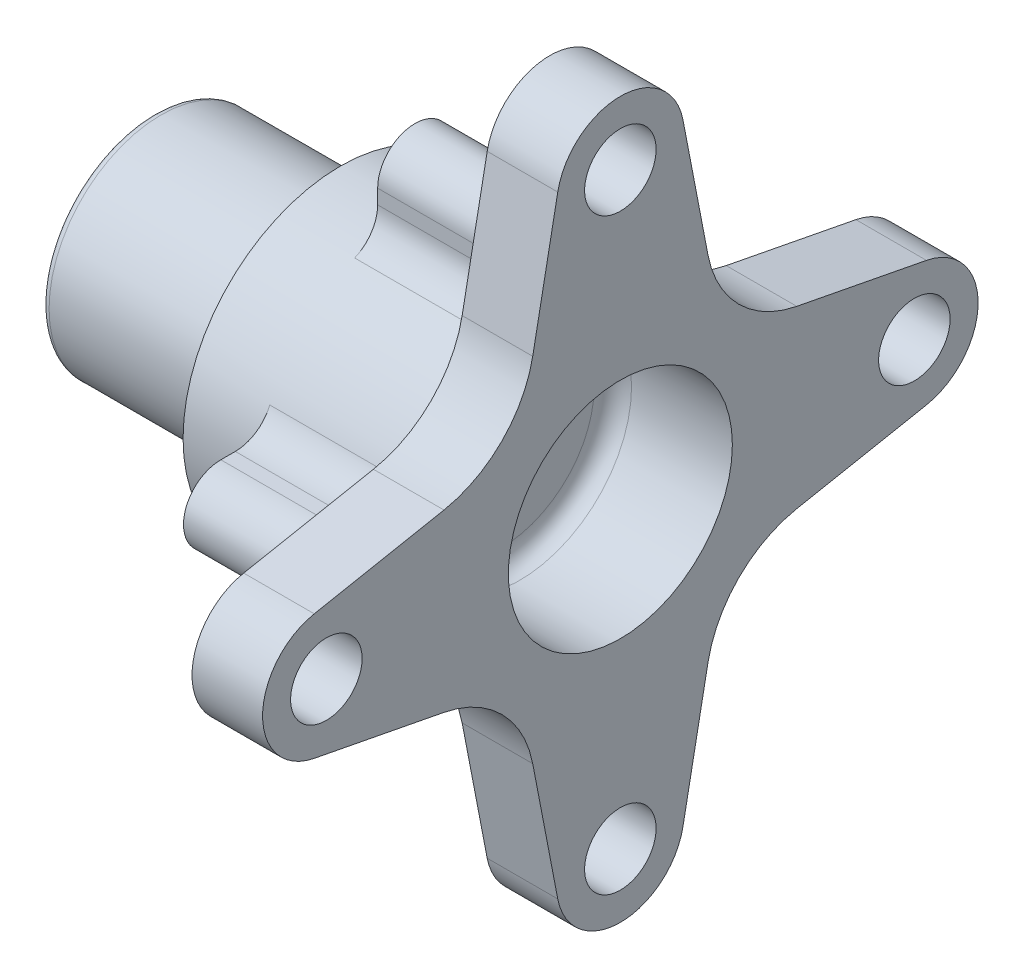
from build123d import *

# Parameters (mm, degrees)
SKETCH2_R                       = 61.1125
SKETCH2_R_2                     = 6.07949
CUT_EXTRUDE1_DEPTH              = 12
F_3_16_0_1875_DOWEL_HOLE1_D     = 4.7625
F_3_16_0_1875_DOWEL_HOLE1_DEPTH = 12.7
F_3_16_0_1875_DOWEL_HOLE1_TIP   = 1.430799
CUT_EXTRUDE3_DEPTH              = 22.925
SKETCH6_R                       = 19.05
CUT_EXTRUDE4_DEPTH              = 20.32
FILLET8_R                       = 6.35
FILLET7_R                       = 1.27
FILLET9_R                       = 3.175
F_1_4_20_TAPPED_HOLE1_D         = 5.1054
F_1_4_20_TAPPED_HOLE1_DEPTH     = 16.51
F_1_4_20_TAPPED_HOLE1_TIP       = 1.533817


with BuildPart() as part:
    # Sketch1 → Revolve1 (revolve)
    with BuildSketch(Plane.XY):
        Polygon((479.941353, 251.46), (511.691353, 251.46), (511.691353, 259.155045), (524.391353, 259.155045), (524.391353, 271.78), (547.316353, 271.78), (547.316353, 293.5225), (559.316353, 293.5225), (559.316353, 238.76), (479.941353, 238.76), align=None)
    revolve(axis=Axis((439.541353, 232.41, 0), (1, 0, 0)))

    # Sketch2 → Cut-Extrude1 (cut)
    with BuildSketch(Plane(origin=(559.316353, 0, 0), x_dir=(0, 0, -1), z_dir=(1, 0, 0))):
        with Locations((0, 232.41)):
            Circle(SKETCH2_R)
        with BuildLine():
            ThreePointArc((-10.645415, 284.46521), (0, 293.25199), (10.645415, 284.46521))
            Line((10.645415, 284.46521), (14.903909, 262.407394))
            ThreePointArc((14.903909, 262.407394), (20.138131, 252.548131), (29.997394, 247.313909))
            Line((29.997394, 247.313909), (52.05521, 243.055415))
            ThreePointArc((52.05521, 243.055415), (58.361558, 239.311673), (60.84199, 232.41))
            ThreePointArc((60.84199, 232.41), (58.361558, 225.508327), (52.05521, 221.764585))
            Line((52.05521, 221.764585), (29.997394, 217.506091))
            ThreePointArc((29.997394, 217.506091), (20.138131, 212.271869), (14.903909, 202.412606))
            Line((14.903909, 202.412606), (10.645415, 180.35479))
            ThreePointArc((10.645415, 180.35479), (0, 171.56801), (-10.645415, 180.35479))
            Line((-10.645415, 180.35479), (-14.903909, 202.412606))
            ThreePointArc((-14.903909, 202.412606), (-14.993612, 202.849678), (-15.093527, 203.284529))
            ThreePointArc((-15.093527, 203.284529), (-19.618803, 211.731698), (-27.684188, 216.906866))
            ThreePointArc((-27.684188, 216.906866), (-28.831386, 217.242784), (-29.997394, 217.506091))
            Line((-29.997394, 217.506091), (-52.05521, 221.764585))
            ThreePointArc((-52.05521, 221.764585), (-60.84199, 232.41), (-52.05521, 243.055415))
            Line((-52.05521, 243.055415), (-29.997394, 247.313909))
            ThreePointArc((-29.997394, 247.313909), (-20.138131, 252.548131), (-14.903909, 262.407394))
            Line((-14.903909, 262.407394), (-10.645415, 284.46521))
        make_face(mode=Mode.SUBTRACT)
        with Locations((-50, 232.41)):
            Circle(SKETCH2_R_2)
        with Locations((0, 182.41)):
            Circle(SKETCH2_R_2)
        with Locations((50, 232.41)):
            Circle(SKETCH2_R_2)
        with Locations((0, 282.41)):
            Circle(SKETCH2_R_2)
    extrude(amount=-CUT_EXTRUDE1_DEPTH, mode=Mode.SUBTRACT)

    # 3/16 (0.1875) Dowel Hole1
    with Locations(Plane(origin=(479.941353, 238.76, -10.998523), x_dir=(0, 0, -1), z_dir=(-1, 0, 0))):
        with Locations((0, 0), (-10.998523, -6.35), (-21.997045, 0), (-21.997045, 12.7), (-10.998523, 19.05), (0, 12.7)):
            Hole(F_3_16_0_1875_DOWEL_HOLE1_D / 2, depth=F_3_16_0_1875_DOWEL_HOLE1_DEPTH)
            with Locations((0, 0, -(F_3_16_0_1875_DOWEL_HOLE1_DEPTH + F_3_16_0_1875_DOWEL_HOLE1_TIP / 2))):  # 118° drill point
                Cone(0, F_3_16_0_1875_DOWEL_HOLE1_D / 2, F_3_16_0_1875_DOWEL_HOLE1_TIP, mode=Mode.SUBTRACT)

    # Sketch5 → Cut-Extrude3 (cut)
    with BuildSketch(Plane.ZY.offset(-524.391353)):
        with BuildLine():
            ThreePointArc((-33.02, 226.06), (-37.510128, 227.919872), (-39.37, 232.41))
            ThreePointArc((-39.37, 232.41), (-27.838794, 204.571206), (0, 193.04))
            ThreePointArc((0, 193.04), (-4.490128, 194.899872), (-6.35, 199.39))
            Line((-6.35, 199.39), (-6.35, 206.42972))
            ThreePointArc((-6.35, 206.42972), (-18.911603, 213.498397), (-25.98028, 226.06))
            Line((-25.98028, 226.06), (-33.02, 226.06))
        make_face()
        with BuildLine():
            Line((-6.35, 258.39028), (-6.35, 265.43))
            ThreePointArc((-6.35, 265.43), (-4.490128, 269.920128), (0, 271.78))
            ThreePointArc((0, 271.78), (-27.838794, 260.248794), (-39.37, 232.41))
            ThreePointArc((-39.37, 232.41), (-37.510128, 236.900128), (-33.02, 238.76))
            Line((-33.02, 238.76), (-25.98028, 238.76))
            ThreePointArc((-25.98028, 238.76), (-18.911603, 251.321603), (-6.35, 258.39028))
        make_face()
        with BuildLine():
            ThreePointArc((39.37, 232.41), (27.838794, 260.248794), (0, 271.78))
            ThreePointArc((0, 271.78), (4.490128, 269.920128), (6.35, 265.43))
            Line((6.35, 265.43), (6.35, 258.39028))
            ThreePointArc((6.35, 258.39028), (18.911603, 251.321603), (25.98028, 238.76))
            Line((25.98028, 238.76), (33.02, 238.76))
            ThreePointArc((33.02, 238.76), (37.510128, 236.900128), (39.37, 232.41))
        make_face()
        with BuildLine():
            ThreePointArc((0, 193.04), (27.838794, 204.571206), (39.37, 232.41))
            ThreePointArc((39.37, 232.41), (37.510128, 227.919872), (33.02, 226.06))
            Line((33.02, 226.06), (25.98028, 226.06))
            ThreePointArc((25.98028, 226.06), (18.911603, 213.498397), (6.35, 206.42972))
            Line((6.35, 206.42972), (6.35, 199.39))
            ThreePointArc((6.35, 199.39), (4.490128, 194.899872), (0, 193.04))
        make_face()
    extrude(amount=-CUT_EXTRUDE3_DEPTH, mode=Mode.SUBTRACT)

    # Sketch6 → Cut-Extrude4 (cut)
    with BuildSketch(Plane(origin=(559.316353, 0, 0), x_dir=(0, 0, -1), z_dir=(1, 0, 0))):
        with Locations((0, 232.41)):
            Circle(SKETCH6_R)
    extrude(amount=-CUT_EXTRUDE4_DEPTH, mode=Mode.SUBTRACT)

    # Fillet8
    fillet8_edges = [part.edges().sort_by_distance(p)[0] for p in [
        (535.853853, 226.06, -25.98028),
        (535.853853, 206.42972, -6.35),
        (535.853853, 258.39028, -6.35),
        (535.853853, 238.76, -25.98028),
        (535.853853, 238.76, 25.98028),
        (535.853853, 258.39028, 6.35),
        (535.853853, 206.42972, 6.35),
        (535.853853, 226.06, 25.98028),
    ]]
    fillet(fillet8_edges, radius=FILLET8_R)

    # Fillet7
    fillet7_edges = [part.edges().sort_by_distance(p)[0] for p in [
        (479.941353, 226.06, 0),
        (479.941353, 213.36, 0),
    ]]
    fillet(fillet7_edges, radius=FILLET7_R)

    # Fillet9
    fillet9_edges = [part.edges().sort_by_distance(p)[0] for p in [
        (538.996353, 232.41, 19.05),
    ]]
    fillet(fillet9_edges, radius=FILLET9_R)

    # 1/4-20 Tapped Hole1
    with Locations(Plane(origin=(524.391353, 232.41, -34.29), x_dir=(0, 0, -1), z_dir=(-1, 0, 0))):
        with Locations((0, 0), (-34.29, -34.29), (-68.58, 0), (-34.29, 34.29)):
            Hole(F_1_4_20_TAPPED_HOLE1_D / 2, depth=F_1_4_20_TAPPED_HOLE1_DEPTH)
            with Locations((0, 0, -(F_1_4_20_TAPPED_HOLE1_DEPTH + F_1_4_20_TAPPED_HOLE1_TIP / 2))):  # 118° drill point
                Cone(0, F_1_4_20_TAPPED_HOLE1_D / 2, F_1_4_20_TAPPED_HOLE1_TIP, mode=Mode.SUBTRACT)


solid = part.part
